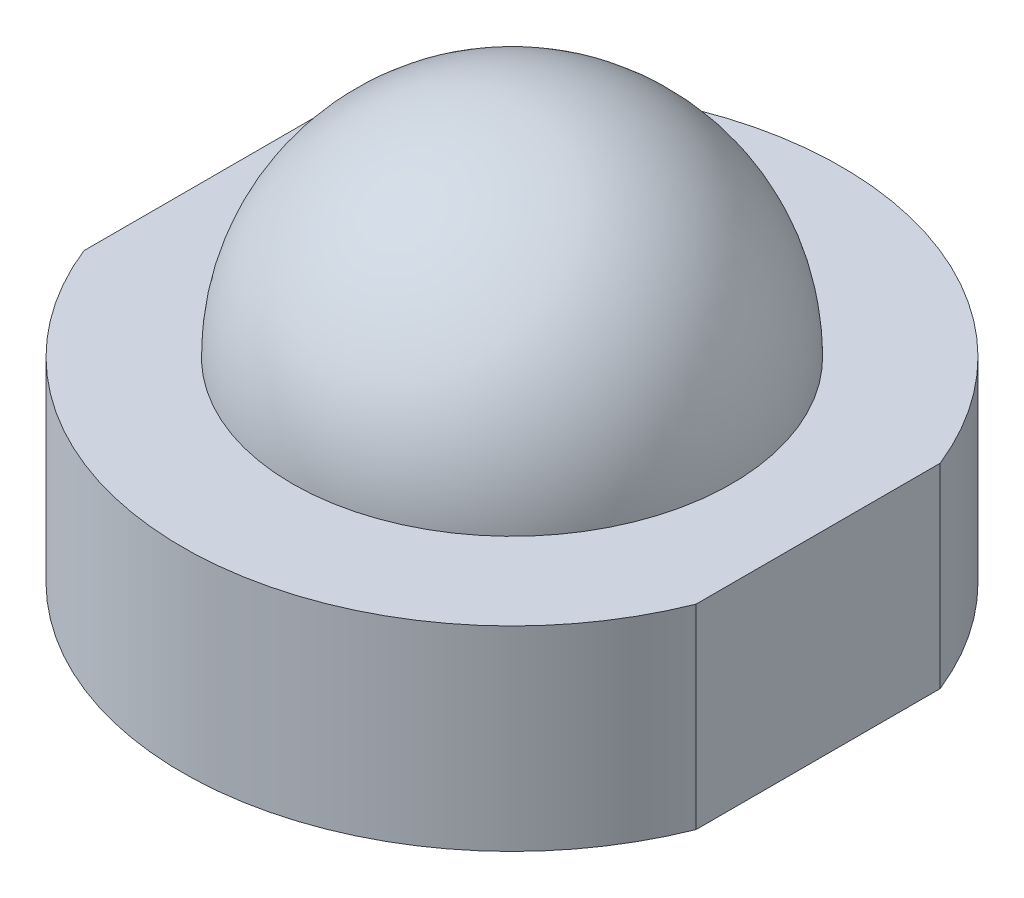
from build123d import *

# Parameters (mm, degrees)
BOSS_EXTRUDE1_DEPTH = 2.4


with BuildPart() as part:
    # Sketch1 → Boss-Extrude1 (new body)
    with BuildSketch(Plane(origin=(0, 0, 0), x_dir=(1, 0, 0), z_dir=(0, 1, 0))):
        with BuildLine():
            Line((3.761980861, -1.5), (3.761980861, 1.5))
            ThreePointArc((3.761980861, 1.5), (0, 4.05), (-3.761980861, 1.5))
            Line((-3.761980861, 1.5), (-3.761980861, -1.5))
            ThreePointArc((-3.761980861, -1.5), (0, -4.05), (3.761980861, -1.5))
        make_face()
    extrude(amount=BOSS_EXTRUDE1_DEPTH)

    # Sketch3 → Revolve1 (revolve)
    with BuildSketch(Plane(origin=(0, 0, 0), x_dir=(0, 0, -1), z_dir=(1, 0, 0))):
        with BuildLine():
            Line((0, 2.4), (0, 5.1))
            ThreePointArc((0, 5.1), (1.909188309, 4.309188309), (2.7, 2.4))
            Line((2.7, 2.4), (0, 2.4))
        make_face()
    revolve(axis=Axis((0, 2.4, 0), (0, 1, 0)))


solid = part.part
